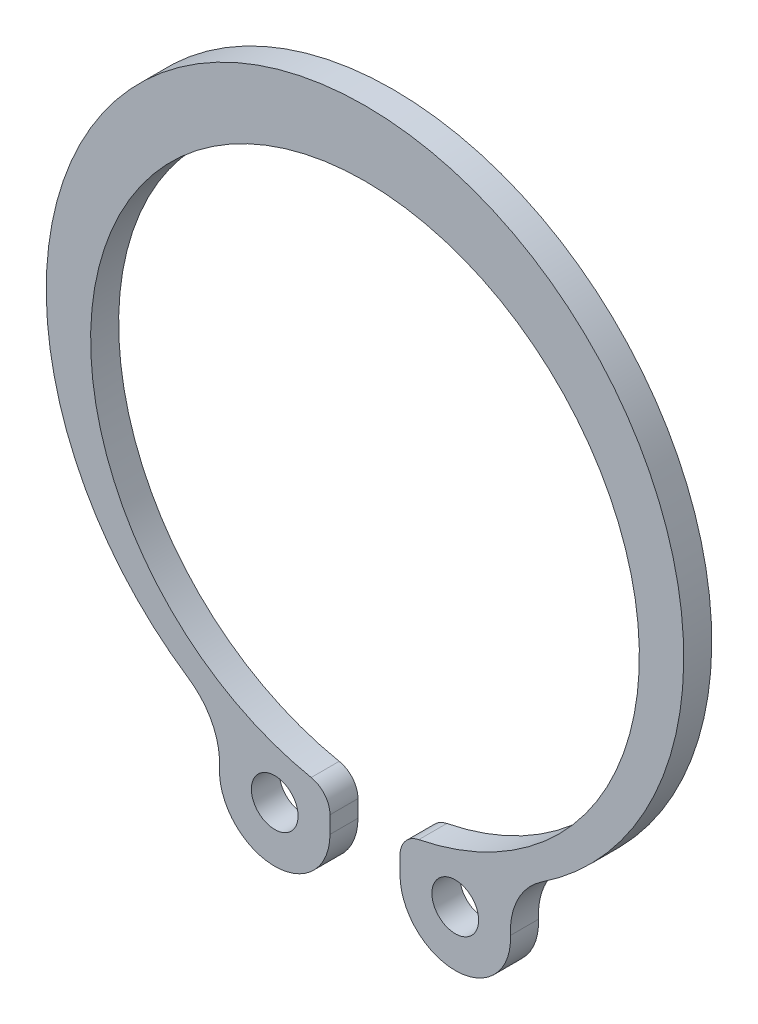
from build123d import *

# Parameters (mm, degrees)
SKETCH_1_R      = 1
EXTRUDE_1_DEPTH = 1.2


with BuildPart() as part:
    # Эскиз1 → Бобышка-Вытянуть1 (new body)
    with BuildSketch(Plane.XY):
        with BuildLine():
            Line((-1.5, -14.13068138), (-1.5, -13.40249975))
            ThreePointArc((-1.5, -13.40249975), (-1.726670047, -12.768495977), (-2.303921569, -12.421911534))
            ThreePointArc((-2.303921569, -12.421911534), (0, 10.85), (2.303921569, -12.421911534))
            ThreePointArc((2.303921569, -12.421911534), (1.726670047, -12.768495977), (1.5, -13.40249975))
            Line((1.5, -13.40249975), (1.5, -14.13068138))
            ThreePointArc((1.5, -14.13068138), (3.925611512, -16.49598173), (6.229101581, -14.011596401))
            ThreePointArc((6.229101581, -14.011596401), (6.545988208, -12.511051934), (7.563083293, -11.363198102))
            ThreePointArc((7.563083293, -11.363198102), (0, 13.65), (-7.563083293, -11.363198102))
            ThreePointArc((-7.563083293, -11.363198102), (-6.545988208, -12.511051934), (-6.229101581, -14.011596401))
            ThreePointArc((-6.229101581, -14.011596401), (-3.925611512, -16.49598173), (-1.5, -14.13068138))
        make_face()
        with Locations((-3.866050148, -14.13068138)):
            Circle(SKETCH_1_R, mode=Mode.SUBTRACT)
        with Locations((3.866050148, -14.13068138)):
            Circle(SKETCH_1_R, mode=Mode.SUBTRACT)
    extrude(amount=EXTRUDE_1_DEPTH)


solid = part.part
